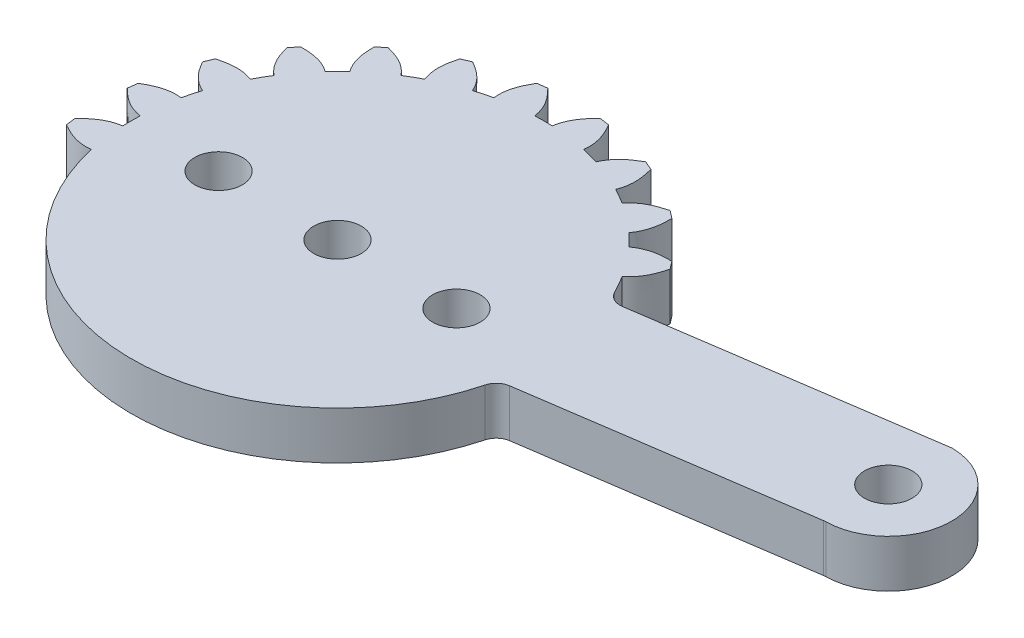
from build123d import *

# Parameters (mm, degrees)
SKETCH1_R           = 1.5
BOSS_EXTRUDE1_DEPTH = 3


with BuildPart() as part:
    # Sketch1 → Boss-Extrude1 (new body)
    with BuildSketch(Plane(origin=(0, 0, 0), x_dir=(1, 0, 0), z_dir=(0, 1, 0))):
        with BuildLine():
            Line((12.632699085, 5.340493617), (30.652467528, 7.988606141))
            ThreePointArc((30.652467528, 7.988606141), (30.736256439, 7.997332941), (30.820482547, 7.998976483))
            ThreePointArc((30.820482547, 7.998976483), (34.729974115, 3.985609874), (30.791707503, 0.000476005))
            ThreePointArc((30.791707503, 0.000476005), (30.726552312, -0.002657016), (30.661739998, -0.010031215))
            Line((30.661739998, -0.010031215), (13.400696346, -2.546644602))
            ThreePointArc((13.400696346, -2.546644602), (12.878710947, -2.791300832), (12.578512819, -3.283445639))
            ThreePointArc((12.578512819, -3.283445639), (0.316986254, -12.996134799), (-12.403478945, -3.892776652))
            add(Edge.make_bspline(
                [(-12.403478945, -3.892776652), (-12.568432388, -3.367671042), (-12.688169827, -2.830255546)],
                knots=[0, 0, 0, 0.029411494, 0.029411494, 0.029411494], degree=2))
            add(Edge.make_bspline(
                [(-12.688169827, -2.830255546), (-13.526378309, -2.92825021), (-14.200348489, -2.631756771), (-14.828036033, -2.264806262)],
                knots=[0, 0, 0, 0, 0.585569533, 0.585569533, 0.585569533, 0.585569533], degree=3))
            add(Edge.make_bspline(
                [(-14.828036033, -2.264806262), (-14.874848849, -1.958311002), (-14.908957951, -1.650143267)],
                knots=[0, 0, 0, 1, 1, 1], degree=2))
            add(Edge.make_bspline(
                [(-12.988354961, -0.550123072), (-13.823365068, -0.672411814), (-14.397632122, -1.133238803), (-14.908957951, -1.650143267)],
                knots=[0, 0, 0, 0, 0.585569533, 0.585569533, 0.585569533, 0.585569533], degree=3))
            add(Edge.make_bspline(
                [(-12.988354961, -0.550123072), (-13.003945727, -0.183508375), (-13.00394681, 0.183466584), (-12.988354961, 0.550123072)],
                knots=[0.090903106, 0.090903106, 0.090903106, 0.090903106, 0.120321184, 0.120321184, 0.120321184, 0.120321184], degree=3))
            add(Edge.make_bspline(
                [(-12.988354961, 0.550123072), (-13.823365068, 0.672411814), (-14.397632122, 1.133238803), (-14.908957951, 1.650143267)],
                knots=[0, 0, 0, 0, 0.585569533, 0.585569533, 0.585569533, 0.585569533], degree=3))
            add(Edge.make_bspline(
                [(-14.908957951, 1.650143267), (-14.874848849, 1.958311002), (-14.828036033, 2.264806262)],
                knots=[0, 0, 0, 1, 1, 1], degree=2))
            add(Edge.make_bspline(
                [(-12.688169827, 2.830255546), (-13.526378309, 2.92825021), (-14.200348489, 2.631756771), (-14.828036033, 2.264806262)],
                knots=[0, 0, 0, 0, 0.585569533, 0.585569533, 0.585569533, 0.585569533], degree=3))
            add(Edge.make_bspline(
                [(-12.688169827, 2.830255546), (-12.60833596, 3.18844173), (-12.513361148, 3.542894104), (-12.40340517, 3.893011712)],
                knots=[0.181812796, 0.181812796, 0.181812796, 0.181812796, 0.211230873, 0.211230873, 0.211230873, 0.211230873], degree=3))
            add(Edge.make_bspline(
                [(-12.40340517, 3.893011712), (-13.178312342, 4.227250084), (-13.613740919, 4.821006025), (-13.973859024, 5.452638259)],
                knots=[0, 0, 0, 0, 0.585569533, 0.585569533, 0.585569533, 0.585569533], degree=3))
            add(Edge.make_bspline(
                [(-13.973859024, 5.452638259), (-13.861152482, 5.741477348), (-13.736607963, 6.025412987)],
                knots=[0, 0, 0, 1, 1, 1], degree=2))
            add(Edge.make_bspline(
                [(-11.523306886, 6.017756925), (-12.307591221, 6.329356822), (-13.035334574, 6.217402469), (-13.736607963, 6.025412987)],
                knots=[0, 0, 0, 0, 0.585569533, 0.585569533, 0.585569533, 0.585569533], degree=3))
            add(Edge.make_bspline(
                [(-11.523306886, 6.017756925), (-11.35348747, 6.343077502), (-11.170010092, 6.660869731), (-10.973183814, 6.970598036)],
                knots=[0.272722485, 0.272722485, 0.272722485, 0.272722485, 0.302140562, 0.302140562, 0.302140562, 0.302140562], degree=3))
            add(Edge.make_bspline(
                [(-10.973183814, 6.970598036), (-11.635179408, 7.494008246), (-11.902095771, 8.180229653), (-12.086464697, 8.883544965)],
                knots=[0, 0, 0, 0, 0.585569533, 0.585569533, 0.585569533, 0.585569533], degree=3))
            add(Edge.make_bspline(
                [(-12.086464697, 8.883544965), (-11.90284148, 9.133371501), (-11.709052762, 9.375397774)],
                knots=[0, 0, 0, 1, 1, 1], degree=2))
            add(Edge.make_bspline(
                [(-9.573149625, 8.795158115), (-10.250062131, 9.299128225), (-10.981984149, 9.379342464), (-11.709052762, 9.375397774)],
                knots=[0, 0, 0, 0, 0.585569533, 0.585569533, 0.585569533, 0.585569533], degree=3))
            add(Edge.make_bspline(
                [(-9.573149625, 8.795158115), (-9.324917477, 9.065441278), (-9.065441275, 9.324917485), (-8.795158115, 9.573149625)],
                knots=[0.363632174, 0.363632174, 0.363632174, 0.363632174, 0.393050251, 0.393050251, 0.393050251, 0.393050251], degree=3))
            add(Edge.make_bspline(
                [(-8.795158115, 9.573149625), (-9.299128225, 10.250062131), (-9.379342464, 10.981984149), (-9.375397774, 11.709052762)],
                knots=[0, 0, 0, 0, 0.585569533, 0.585569533, 0.585569533, 0.585569533], degree=3))
            add(Edge.make_bspline(
                [(-9.375397774, 11.709052762), (-9.133371501, 11.90284148), (-8.883544965, 12.086464697)],
                knots=[0, 0, 0, 1, 1, 1], degree=2))
            add(Edge.make_bspline(
                [(-6.970598036, 10.973183814), (-7.494008246, 11.635179408), (-8.180229653, 11.902095771), (-8.883544965, 12.086464697)],
                knots=[0, 0, 0, 0, 0.585569533, 0.585569533, 0.585569533, 0.585569533], degree=3))
            add(Edge.make_bspline(
                [(-6.970598036, 10.973183814), (-6.660869762, 11.170010102), (-6.343077615, 11.353487483), (-6.017756925, 11.523306886)],
                knots=[0.454541863, 0.454541863, 0.454541863, 0.454541863, 0.48395994, 0.48395994, 0.48395994, 0.48395994], degree=3))
            add(Edge.make_bspline(
                [(-6.017756925, 11.523306886), (-6.329356822, 12.307591221), (-6.217402469, 13.035334574), (-6.025412987, 13.736607963)],
                knots=[0, 0, 0, 0, 0.585569533, 0.585569533, 0.585569533, 0.585569533], degree=3))
            add(Edge.make_bspline(
                [(-6.025412987, 13.736607963), (-5.741477348, 13.861152482), (-5.452638259, 13.973859024)],
                knots=[0, 0, 0, 1, 1, 1], degree=2))
            add(Edge.make_bspline(
                [(-3.893011712, 12.40340517), (-4.227250084, 13.178312342), (-4.821006025, 13.613740919), (-5.452638259, 13.973859024)],
                knots=[0, 0, 0, 0, 0.585569533, 0.585569533, 0.585569533, 0.585569533], degree=3))
            add(Edge.make_bspline(
                [(-3.893011712, 12.40340517), (-3.54289478, 12.513361188), (-3.188443695, 12.608336067), (-2.830255546, 12.688169827)],
                knots=[0.545451553, 0.545451553, 0.545451553, 0.545451553, 0.57486963, 0.57486963, 0.57486963, 0.57486963], degree=3))
            add(Edge.make_bspline(
                [(-2.830255546, 12.688169827), (-2.92825021, 13.526378309), (-2.631756771, 14.200348489), (-2.264806262, 14.828036033)],
                knots=[0, 0, 0, 0, 0.585569533, 0.585569533, 0.585569533, 0.585569533], degree=3))
            add(Edge.make_bspline(
                [(-2.264806262, 14.828036033), (-1.958311002, 14.874848849), (-1.650143267, 14.908957951)],
                knots=[0, 0, 0, 1, 1, 1], degree=2))
            add(Edge.make_bspline(
                [(-0.550123072, 12.988354961), (-0.672411814, 13.823365068), (-1.133238803, 14.397632122), (-1.650143267, 14.908957951)],
                knots=[0, 0, 0, 0, 0.585569533, 0.585569533, 0.585569533, 0.585569533], degree=3))
            add(Edge.make_bspline(
                [(-0.550123072, 12.988354961), (-0.183477364, 13.003947374), (0.183477419, 13.003947344), (0.550123072, 12.988354961)],
                knots=[0.636361242, 0.636361242, 0.636361242, 0.636361242, 0.665779319, 0.665779319, 0.665779319, 0.665779319], degree=3))
            add(Edge.make_bspline(
                [(0.550123072, 12.988354961), (0.672411814, 13.823365068), (1.133238803, 14.397632122), (1.650143267, 14.908957951)],
                knots=[0, 0, 0, 0, 0.585569533, 0.585569533, 0.585569533, 0.585569533], degree=3))
            add(Edge.make_bspline(
                [(1.650143267, 14.908957951), (1.958311002, 14.874848849), (2.264806262, 14.828036033)],
                knots=[0, 0, 0, 1, 1, 1], degree=2))
            add(Edge.make_bspline(
                [(2.830255546, 12.688169827), (2.92825021, 13.526378309), (2.631756771, 14.200348489), (2.264806262, 14.828036033)],
                knots=[0, 0, 0, 0, 0.585569533, 0.585569533, 0.585569533, 0.585569533], degree=3))
            add(Edge.make_bspline(
                [(2.830255546, 12.688169827), (3.188443874, 12.608335818), (3.542895259, 12.513360471), (3.893011712, 12.40340517)],
                knots=[0.727270931, 0.727270931, 0.727270931, 0.727270931, 0.756689008, 0.756689008, 0.756689008, 0.756689008], degree=3))
            add(Edge.make_bspline(
                [(3.893011712, 12.40340517), (4.227250084, 13.178312342), (4.821006025, 13.613740919), (5.452638259, 13.973859024)],
                knots=[0, 0, 0, 0, 0.585569533, 0.585569533, 0.585569533, 0.585569533], degree=3))
            add(Edge.make_bspline(
                [(5.452638259, 13.973859024), (5.741477348, 13.861152482), (6.025412987, 13.736607963)],
                knots=[0, 0, 0, 1, 1, 1], degree=2))
            add(Edge.make_bspline(
                [(6.017756925, 11.523306886), (6.329356822, 12.307591221), (6.217402469, 13.035334574), (6.025412987, 13.736607963)],
                knots=[0, 0, 0, 0, 0.585569533, 0.585569533, 0.585569533, 0.585569533], degree=3))
            add(Edge.make_bspline(
                [(6.017756925, 11.523306886), (6.343080162, 11.353483585), (6.660877044, 11.16999893), (6.970598036, 10.973183814)],
                knots=[0.81818062, 0.81818062, 0.81818062, 0.81818062, 0.847598697, 0.847598697, 0.847598697, 0.847598697], degree=3))
            add(Edge.make_bspline(
                [(6.970598036, 10.973183814), (7.494008246, 11.635179408), (8.180229653, 11.902095771), (8.883544965, 12.086464697)],
                knots=[0, 0, 0, 0, 0.585569533, 0.585569533, 0.585569533, 0.585569533], degree=3))
            add(Edge.make_bspline(
                [(8.883544965, 12.086464697), (9.133371501, 11.90284148), (9.375397774, 11.709052762)],
                knots=[0, 0, 0, 1, 1, 1], degree=2))
            add(Edge.make_bspline(
                [(8.795158115, 9.573149625), (9.299128225, 10.250062131), (9.379342464, 10.981984149), (9.375397774, 11.709052762)],
                knots=[0, 0, 0, 0, 0.585569533, 0.585569533, 0.585569533, 0.585569533], degree=3))
            add(Edge.make_bspline(
                [(8.795158115, 9.573149625), (9.065480928, 9.3248566), (9.325031193, 9.065266643), (9.573149625, 8.795158115)],
                knots=[0.909090309, 0.909090309, 0.909090309, 0.909090309, 0.938508386, 0.938508386, 0.938508386, 0.938508386], degree=3))
            add(Edge.make_bspline(
                [(9.573149625, 8.795158115), (10.250062131, 9.299128225), (10.981984149, 9.379342464), (11.709052762, 9.375397774)],
                knots=[0, 0, 0, 0, 0.585569533, 0.585569533, 0.585569533, 0.585569533], degree=3))
            add(Edge.make_bspline(
                [(11.709052762, 9.375397774), (11.90284148, 9.133371501), (12.086464697, 8.883544965)],
                knots=[0, 0, 0, 1, 1, 1], degree=2))
            add(Edge.make_bspline(
                [(10.973183814, 6.970598036), (11.635179408, 7.494008246), (11.902095771, 8.180229653), (12.086464697, 8.883544965)],
                knots=[0, 0, 0, 0, 0.585569533, 0.585569533, 0.585569533, 0.585569533], degree=3))
            ThreePointArc((10.973183814, 6.970598036), (11.297491618, 6.431693645), (11.595354368, 5.87773401))
            ThreePointArc((11.595354368, 5.87773401), (12.027420742, 5.441888374), (12.632699085, 5.340493617))
        make_face()
        Circle(SKETCH1_R, mode=Mode.SUBTRACT)
        with Locations((7.5, 0)):
            Circle(SKETCH1_R, mode=Mode.SUBTRACT)
        with Locations((-7.5, 0)):
            Circle(SKETCH1_R, mode=Mode.SUBTRACT)
        with Locations((30.73, 4)):
            Circle(SKETCH1_R, mode=Mode.SUBTRACT)
    extrude(amount=BOSS_EXTRUDE1_DEPTH)


solid = part.part
